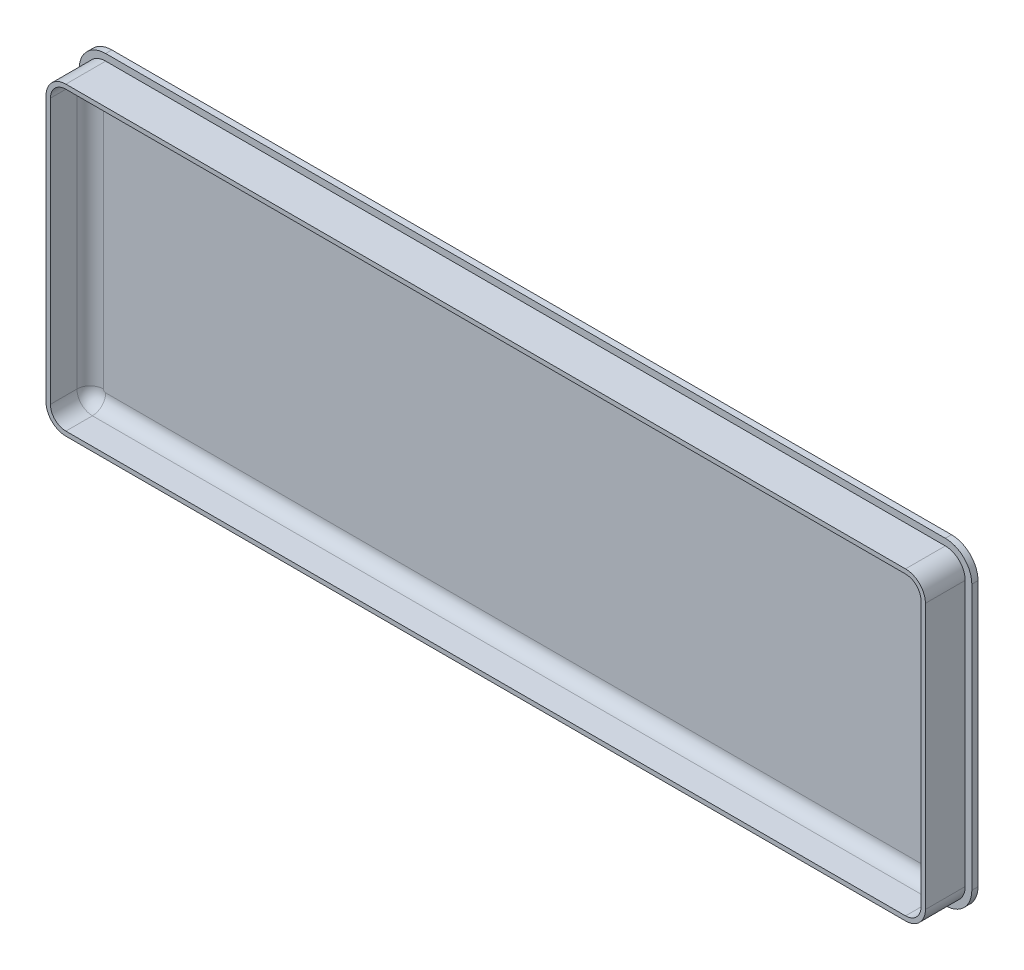
from build123d import *

# Parameters (mm, degrees)
SKETCH1_W           = 202
SKETCH1_H           = 72
BOSS_EXTRUDE1_DEPTH = 1.4
SKETCH2_W           = 199
SKETCH2_H           = 69
SKETCH2_W_2         = 197
SKETCH2_H_2         = 67
BOSS_EXTRUDE2_DEPTH = 9
FILLET1_R           = 3.5
FILLET2_R           = 4.5
FILLET3_R           = 6
FILLET4_R           = 3


with BuildPart() as part:
    # Sketch1 → Boss-Extrude1 (new body)
    with BuildSketch(Plane.XY):
        with Locations((101, 36)):
            Rectangle(SKETCH1_W, SKETCH1_H)
    extrude(amount=BOSS_EXTRUDE1_DEPTH)

    # Sketch2 → Boss-Extrude2 (add)
    with BuildSketch(Plane.XY.offset(1.4)):
        with Locations((101, 36)):
            Rectangle(SKETCH2_W, SKETCH2_H)
        with Locations((101, 36)):
            Rectangle(SKETCH2_W_2, SKETCH2_H_2, mode=Mode.SUBTRACT)
    extrude(amount=BOSS_EXTRUDE2_DEPTH)

    # Fillet1
    fillet1_edges = [part.edges().sort_by_distance(p)[0] for p in [
        (2.5, 2.5, 5.9),
        (199.5, 2.5, 5.9),
        (199.5, 69.5, 5.9),
        (2.5, 69.5, 5.9),
    ]]
    fillet(fillet1_edges, radius=FILLET1_R)

    # Fillet2
    fillet2_edges = [part.edges().sort_by_distance(p)[0] for p in [
        (1.5, 70.5, 5.9),
        (1.5, 1.5, 5.9),
        (200.5, 1.5, 5.9),
        (200.5, 70.5, 5.9),
    ]]
    fillet(fillet2_edges, radius=FILLET2_R)

    # Fillet3
    fillet3_edges = [part.edges().sort_by_distance(p)[0] for p in [
        (0, 72, 0.7),
        (202, 72, 0.7),
        (202, 0, 0.7),
        (0, 0, 0.7),
    ]]
    fillet(fillet3_edges, radius=FILLET3_R)

    # Fillet4
    fillet4_edges = [part.edges().sort_by_distance(p)[0] for p in [
        (101, 69.5, 1.4),
        (2.5, 36, 1.4),
        (101, 2.5, 1.4),
        (199.5, 36, 1.4),
        (198.474873734, 3.525126266, 1.4),
        (198.474873734, 68.474873734, 1.4),
        (3.525126266, 3.525126266, 1.4),
        (3.525126266, 68.474873734, 1.4),
    ]]
    fillet(fillet4_edges, radius=FILLET4_R)


solid = part.part
